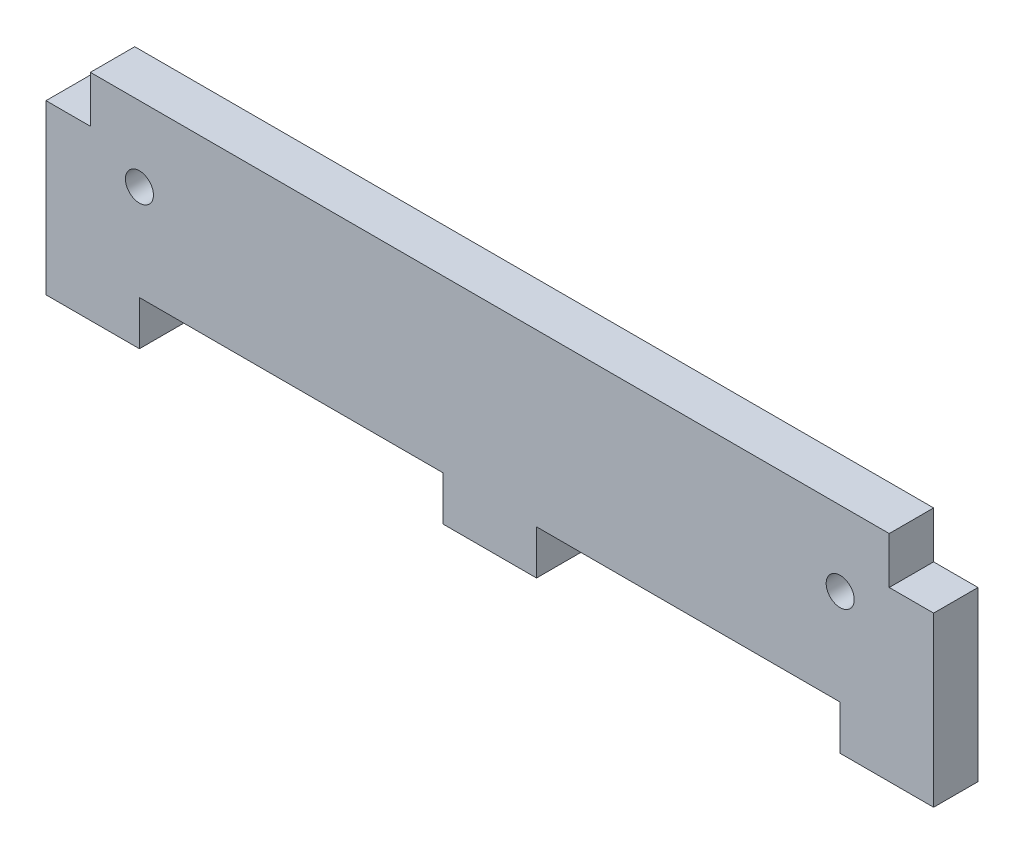
from build123d import *

# Parameters (mm, degrees)
SKETCH1_W           = 95
SKETCH1_H           = 23
BOSS_EXTRUDE1_DEPTH = 4.75
SKETCH2_W           = 32.5
SKETCH2_H           = 4.75
CUT_EXTRUDE1_DEPTH  = 5.75
SKETCH4_R           = 1.5
CUT_EXTRUDE2_DEPTH  = 5.75
SKETCH5_W           = 4.75
SKETCH5_H           = 5
CUT_EXTRUDE3_DEPTH  = 5.75


with BuildPart() as part:
    # Sketch1 → Boss-Extrude1 (new body)
    with BuildSketch(Plane.XY):
        with Locations((47.5, 11.5)):
            Rectangle(SKETCH1_W, SKETCH1_H)
    extrude(amount=BOSS_EXTRUDE1_DEPTH)

    # Sketch2 → Cut-Extrude1 (cut, through all)
    with BuildSketch(Plane.XY.offset(4.75)):
        with Locations((26.25, 2.375)):
            Rectangle(SKETCH2_W, SKETCH2_H)
        with Locations((68.75, 2.375)):
            Rectangle(SKETCH2_W, SKETCH2_H)
    extrude(amount=-CUT_EXTRUDE1_DEPTH, mode=Mode.SUBTRACT)

    # Sketch4 → Cut-Extrude2 (cut, through all)
    with BuildSketch(Plane.XY.offset(4.75)):
        with Locations((10, 15)):
            Circle(SKETCH4_R)
        with Locations((85, 15)):
            Circle(SKETCH4_R)
    extrude(amount=-CUT_EXTRUDE2_DEPTH, mode=Mode.SUBTRACT)

    # Sketch5 → Cut-Extrude3 (cut, through all)
    with BuildSketch(Plane.XY.offset(4.75)):
        with Locations((2.375, 20.5)):
            Rectangle(SKETCH5_W, SKETCH5_H)
        with Locations((92.625, 20.5)):
            Rectangle(SKETCH5_W, SKETCH5_H)
    extrude(amount=-CUT_EXTRUDE3_DEPTH, mode=Mode.SUBTRACT)


solid = part.part
